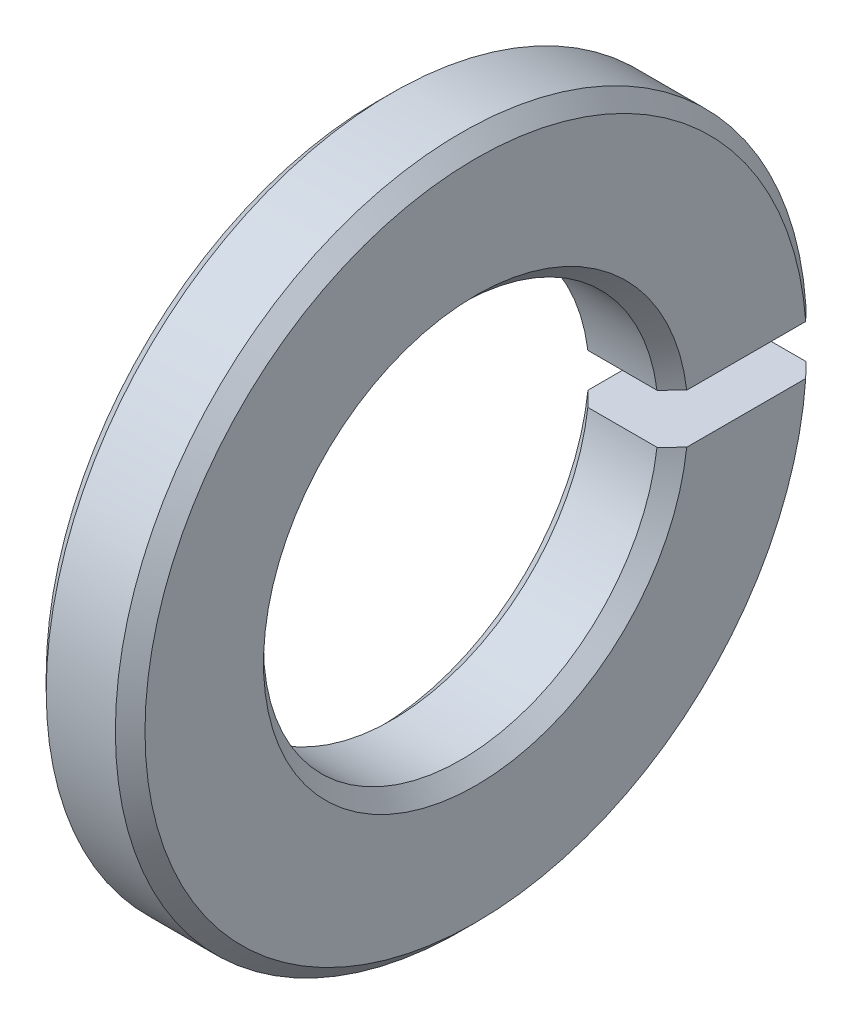
from build123d import *

# Parameters (mm, degrees)
BOSS_EXTRUDE1_DEPTH = 2
CHAMFER1_SIZE       = 0.3


with BuildPart() as part:
    # Sketch1 → Boss-Extrude1 (new body)
    with BuildSketch(Plane(origin=(0, 0, 0), x_dir=(0, 0, -1), z_dir=(1, 0, 0))):
        with BuildLine():
            Line((3.968626967, 0.5), (6.982120022, 0.5))
            ThreePointArc((6.982120022, 0.5), (-7, 0), (6.982120022, -0.5))
            Line((6.982120022, -0.5), (3.968626967, -0.5))
            ThreePointArc((3.968626967, -0.5), (-4, 0), (3.968626967, 0.5))
        make_face()
    extrude(amount=BOSS_EXTRUDE1_DEPTH)

    # Chamfer1
    chamfer1_edges = [part.edges().sort_by_distance(p)[0] for p in [
        (2, 0, 4),
        (2, 0, 7),
        (0, 0, 4),
        (0, 0, 7),
    ]]
    chamfer(chamfer1_edges, length=CHAMFER1_SIZE)


solid = part.part
